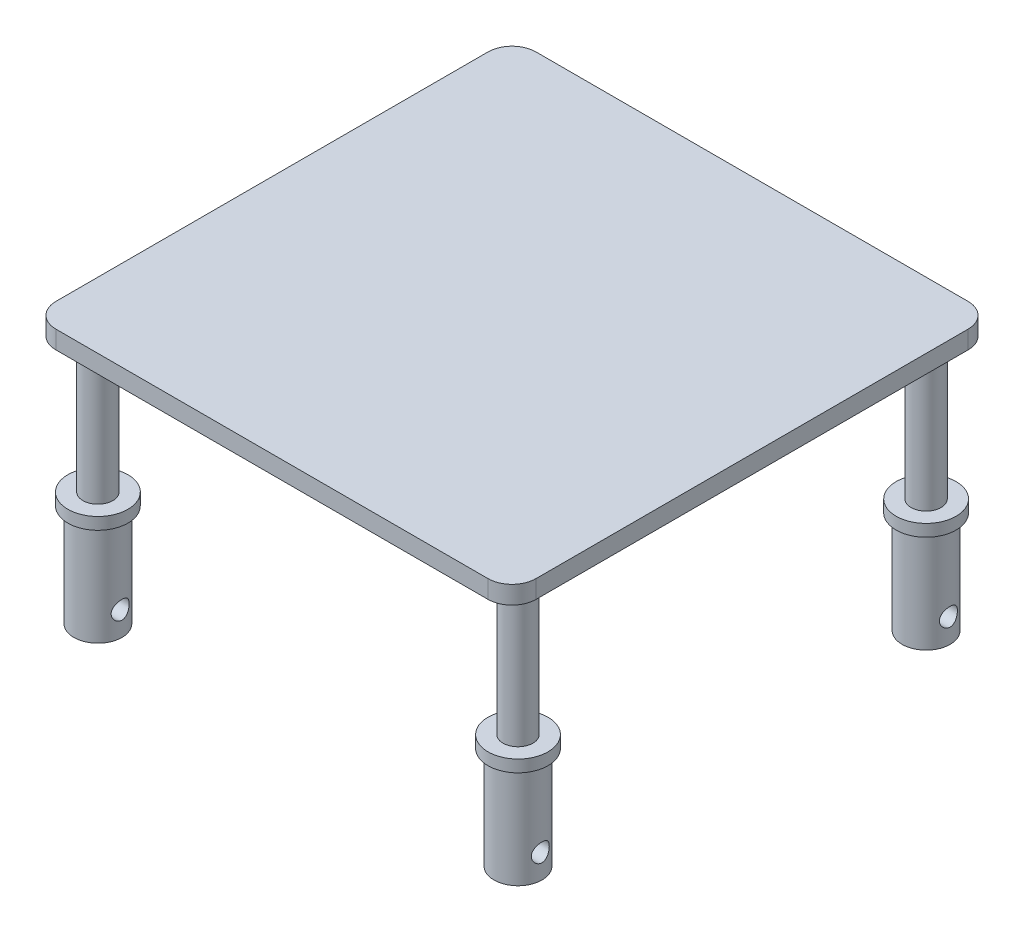
from build123d import *

# Parameters (mm, degrees)
SKETCH1_R               = 2.5
BOSS_EXTRUDE1_DEPTH     = 3
SKETCH1_3_R             = 2.5
BOSS_EXTRUDE2_DEPTH     = 42
SKETCH2_R               = 1.5
CUT_EXTRUDE1_DEPTH      = 147
BOSS_EXTRUDE3_START     = 23
SKETCH3_R               = 5
BOSS_EXTRUDE3_DEPTH     = 2
SKETCH4_R               = 4
BOSS_EXTRUDE4_DEPTH     = 17
SKETCH2_3_R             = 1.5
CUT_EXTRUDE2_DEPTH      = 101
CUT_EXTRUDE2_DEPTH_BACK = 130


with BuildPart() as part:
    # Sketch1 → Boss-Extrude1 (new body)
    with BuildSketch(Plane(origin=(0, 0, 0), x_dir=(1, 0, 0), z_dir=(0, 1, 0))):
        with BuildLine():
            ThreePointArc((-40, 36), (-38.828427125, 38.828427125), (-36, 40))
            Line((-36, 40), (36, 40))
            ThreePointArc((36, 40), (38.828427125, 38.828427125), (40, 36))
            Line((40, 36), (40, -36))
            ThreePointArc((40, -36), (38.828427125, -38.828427125), (36, -40))
            Line((36, -40), (-36, -40))
            ThreePointArc((-36, -40), (-38.828427125, -38.828427125), (-40, -36))
            Line((-40, -36), (-40, 36))
        make_face()
        with Locations((35, 34)):
            Circle(SKETCH1_R, mode=Mode.SUBTRACT)
        with Locations((35, -34)):
            Circle(SKETCH1_R, mode=Mode.SUBTRACT)
        with Locations((-35, -34)):
            Circle(SKETCH1_R, mode=Mode.SUBTRACT)
        with Locations((-35, 34)):
            Circle(SKETCH1_R, mode=Mode.SUBTRACT)
        with Locations((-35, 34)):
            Circle(SKETCH1_R)
        with Locations((35, 34)):
            Circle(SKETCH1_R)
        with Locations((-35, -34)):
            Circle(SKETCH1_R)
        with Locations((35, -34)):
            Circle(SKETCH1_R)
    extrude(amount=BOSS_EXTRUDE1_DEPTH)

    # Sketch1_3 → Boss-Extrude2 (add)
    with BuildSketch(Plane(origin=(0, 0, 0), x_dir=(1, 0, 0), z_dir=(0, 1, 0))):
        with Locations((-35, 34)):
            Circle(SKETCH1_3_R)
        with Locations((-35, -34)):
            Circle(SKETCH1_3_R)
        with Locations((35, -34)):
            Circle(SKETCH1_3_R)
        with Locations((35, 34)):
            Circle(SKETCH1_3_R)
    extrude(amount=-BOSS_EXTRUDE2_DEPTH)

    # Sketch2 → Cut-Extrude1 (cut)
    with BuildSketch(Plane.ZY.offset(37.5)):
        with Locations((-34, -38)):
            Circle(SKETCH2_R)
        with Locations((34, -38)):
            Circle(SKETCH2_R)
    extrude(amount=-CUT_EXTRUDE1_DEPTH, mode=Mode.SUBTRACT)

    # Sketch3 → Boss-Extrude3 (add)
    with BuildSketch(Plane.XZ.offset(BOSS_EXTRUDE3_START)):
        with Locations((35, 34)):
            Circle(SKETCH3_R)
        with Locations((-35, 34)):
            Circle(SKETCH3_R)
        with Locations((-35, -34)):
            Circle(SKETCH3_R)
        with Locations((35, -34)):
            Circle(SKETCH3_R)
    extrude(amount=BOSS_EXTRUDE3_DEPTH)

    # Sketch4 → Boss-Extrude4 (add)
    with BuildSketch(Plane.XZ.offset(25)):
        with Locations((-35, 34)):
            Circle(SKETCH4_R)
        with Locations((35, 34)):
            Circle(SKETCH4_R)
        with Locations((-35, -34)):
            Circle(SKETCH4_R)
        with Locations((35, -34)):
            Circle(SKETCH4_R)
    extrude(amount=BOSS_EXTRUDE4_DEPTH)

    # Sketch2_3 → Cut-Extrude2 (cut, two sides)
    with BuildSketch(Plane.ZY.offset(37.5)) as cut_extrude2_sk:
        with Locations((-34, -38)):
            Circle(SKETCH2_3_R)
        with Locations((34, -38)):
            Circle(SKETCH2_3_R)
    extrude(amount=CUT_EXTRUDE2_DEPTH, mode=Mode.SUBTRACT)
    extrude(cut_extrude2_sk.sketch, amount=-CUT_EXTRUDE2_DEPTH_BACK, mode=Mode.SUBTRACT)


solid = part.part
